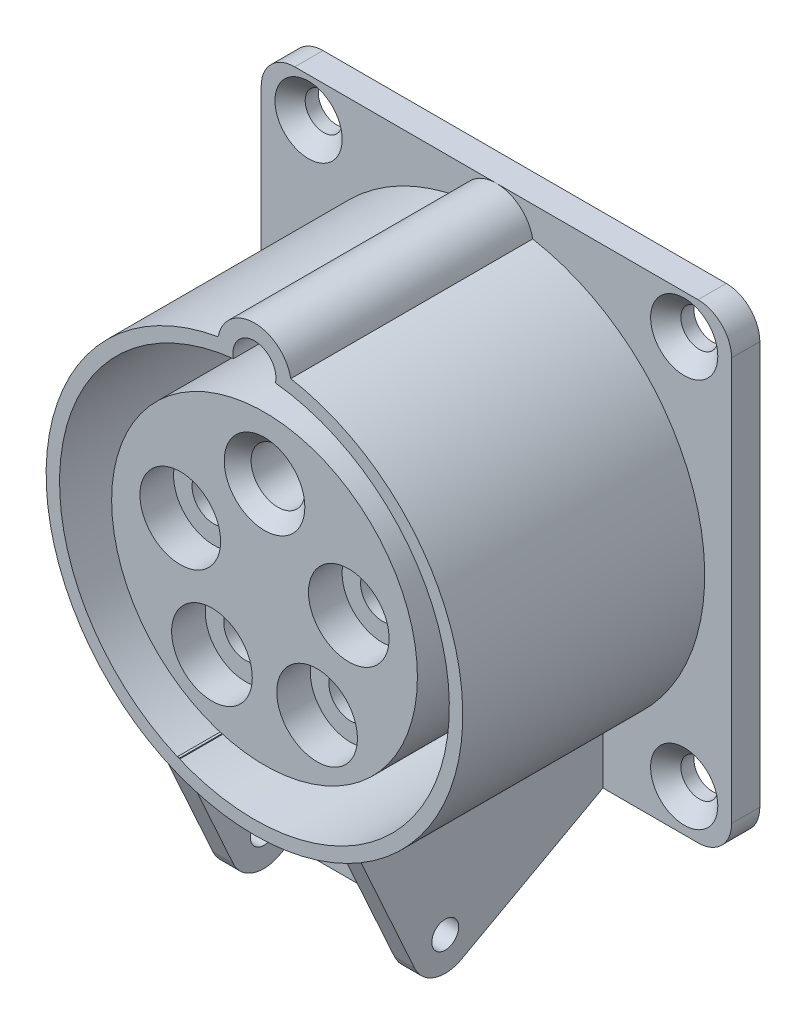
from build123d import *

# Parameters (mm, degrees)
BOSS_EXTRUDE1_DEPTH      = 36
SKETCH4_W                = 70
SKETCH4_H                = 70
SKETCH4_R                = 2.75
BOSS_EXTRUDE2_DEPTH      = 4.2
FILLET1_R                = 5
SKETCH3_R                = 22.75
CUT_EXTRUDE1_DEPTH       = 38.5
SKETCH7_R                = 22.75
CUT_EXTRUDE2_DEPTH       = 1.5
SKETCH9_R                = 6
CUT_EXTRUDE3_DEPTH       = 5
SKETCH11_R               = 3.25
CUT_EXTRUDE4_DEPTH       = 12
SKETCH12_R               = 4
CUT_EXTRUDE5_DEPTH       = 22.7
SKETCH14_R               = 4
CUT_EXTRUDE6_DEPTH       = 8
CHAMFER1_SIZE            = 2
SKETCH15_R               = 5
CUT_EXTRUDE7_DEPTH       = 31.7
SKETCH16_R               = 27.5
SKETCH16_R_2             = 25.2
BOSS_EXTRUDE3_DEPTH      = 2.7
SKETCH17_R               = 2
BOSS_EXTRUDE4_DEPTH      = 3
BOSS_EXTRUDE5_DEPTH      = 0.8
BOSS_EXTRUDE5_DEPTH_BACK = 0.8
SKETCH20_W               = 24
SKETCH20_H               = 22.523679835
BOSS_EXTRUDE6_DEPTH      = 2
FILLET2_R                = 5
CHAMFER2_SIZE            = 2.25


with BuildPart() as part:
    # Sketch2 → Boss-Extrude1 (new body)
    with BuildSketch(Plane.XY):
        with BuildLine():
            ThreePointArc((-6.268429979, 33.450707057), (-0.864865769, -28.074716672), (4.538698442, 33.450707057))
            ThreePointArc((4.538698442, 33.450707057), (-0.864865769, 37.925283328), (-6.268429979, 33.450707057))
        make_face()
    extrude(amount=BOSS_EXTRUDE1_DEPTH)

    # Sketch4 → Boss-Extrude2 (add)
    with BuildSketch(Plane(origin=(0, 0, 0), x_dir=(-1, 0, 0), z_dir=(0, 0, -1))):
        with Locations((0.864865769, 2.925283328)):
            Rectangle(SKETCH4_W, SKETCH4_H)
        with Locations((-27.085134231, -25.824716672)):
            Circle(SKETCH4_R, mode=Mode.SUBTRACT)
        with Locations((-27.085134231, 32.109962946)):
            Circle(SKETCH4_R, mode=Mode.SUBTRACT)
        with Locations((28.814865769, 32.109962946)):
            Circle(SKETCH4_R, mode=Mode.SUBTRACT)
        with Locations((28.814865769, -25.824716672)):
            Circle(SKETCH4_R, mode=Mode.SUBTRACT)
    extrude(amount=BOSS_EXTRUDE2_DEPTH)

    # Fillet1
    fillet1_edges = [part.edges().sort_by_distance(p)[0] for p in [
        (-35.864865769, -32.074716672, -2.1),
        (-35.864865769, 37.925283328, -2.1),
        (34.135134231, 37.925283328, -2.1),
        (34.135134231, -32.074716672, -2.1),
    ]]
    fillet(fillet1_edges, radius=FILLET1_R)

    # Sketch3 → Cut-Extrude1 (cut)
    with BuildSketch(Plane.XY.offset(36)):
        with BuildLine():
            ThreePointArc((-3.994084204, 31.755961294), (-0.864865769, -26.074716672), (2.264352666, 31.755961294))
            ThreePointArc((2.264352666, 31.755961294), (-0.864865769, 35.625283328), (-3.994084204, 31.755961294))
        make_face()
        with Locations((-0.864865769, 2.925283328)):
            Circle(SKETCH3_R, mode=Mode.SUBTRACT)
    extrude(amount=-CUT_EXTRUDE1_DEPTH, mode=Mode.SUBTRACT)

    # Sketch7 → Cut-Extrude2 (cut)
    with BuildSketch(Plane.XY.offset(36)):
        with Locations((-0.864865769, 2.925283328)):
            Circle(SKETCH7_R)
    extrude(amount=-CUT_EXTRUDE2_DEPTH, mode=Mode.SUBTRACT)

    # Sketch9 → Cut-Extrude3 (cut)
    with BuildSketch(Plane.XY.offset(34.5)):
        with Locations((-8.68550449, -9.468077043)):
            Circle(SKETCH9_R)
        with Locations((-13.403571753, 5.757891252)):
            Circle(SKETCH9_R)
        with Locations((11.673840215, 5.757891252)):
            Circle(SKETCH9_R)
        with Locations((6.955772953, -9.468077043)):
            Circle(SKETCH9_R)
    extrude(amount=-CUT_EXTRUDE3_DEPTH, mode=Mode.SUBTRACT)

    # Sketch11 → Cut-Extrude4 (cut)
    with BuildSketch(Plane.XY.offset(29.5)):
        with Locations((11.673840215, 5.757891252)):
            Circle(SKETCH11_R)
        with Locations((-13.403571753, 5.757891252)):
            Circle(SKETCH11_R)
        with Locations((-8.68550449, -9.468077043)):
            Circle(SKETCH11_R)
        with Locations((6.955772953, -9.468077043)):
            Circle(SKETCH11_R)
    extrude(amount=-CUT_EXTRUDE4_DEPTH, mode=Mode.SUBTRACT)

    # Sketch12 → Cut-Extrude5 (cut, through all)
    with BuildSketch(Plane.XY.offset(17.5)):
        with Locations((11.673840215, 5.757891252)):
            Circle(SKETCH12_R)
        with Locations((6.955772953, -9.468077043)):
            Circle(SKETCH12_R)
        with Locations((-8.68550449, -9.468077043)):
            Circle(SKETCH12_R)
        with Locations((-13.403571753, 5.757891252)):
            Circle(SKETCH12_R)
    extrude(amount=-CUT_EXTRUDE5_DEPTH, mode=Mode.SUBTRACT)

    # Sketch14 → Cut-Extrude6 (cut)
    with BuildSketch(Plane.XY.offset(34.5)):
        with Locations((-0.864865769, 16.425283328)):
            Circle(SKETCH14_R)
    extrude(amount=-CUT_EXTRUDE6_DEPTH, mode=Mode.SUBTRACT)

    # Chamfer1
    chamfer1_edges = [part.edges().sort_by_distance(p)[0] for p in [
        (-4.864865769, 16.425283328, 34.5),
    ]]
    chamfer(chamfer1_edges, length=CHAMFER1_SIZE)

    # Sketch15 → Cut-Extrude7 (cut, through all)
    with BuildSketch(Plane.XY.offset(26.5)):
        with Locations((-0.864865769, 16.425283328)):
            Circle(SKETCH15_R)
    extrude(amount=-CUT_EXTRUDE7_DEPTH, mode=Mode.SUBTRACT)

    # Sketch16 → Boss-Extrude3 (add)
    with BuildSketch(Plane(origin=(0, 0, -4.2), x_dir=(-1, 0, 0), z_dir=(0, 0, -1))):
        with Locations((0.864865769, 2.925283328)):
            Circle(SKETCH16_R)
        with Locations((0.864865769, 2.925283328)):
            Circle(SKETCH16_R_2, mode=Mode.SUBTRACT)
    extrude(amount=BOSS_EXTRUDE3_DEPTH)

    # Sketch17 → Boss-Extrude4 (add)
    with BuildSketch(Plane(origin=(15, 0, 0), x_dir=(0, 0, -1), z_dir=(1, 0, 0))):
        Polygon((-36, -23.70751664), (-25.8, -46.20751664), (0, -32.074716672), (0, -23.70751664), align=None)
        with Locations((-23.472627315, -39.231599401)):
            Circle(SKETCH17_R, mode=Mode.SUBTRACT)
    boss_extrude4 = extrude(amount=-BOSS_EXTRUDE4_DEPTH)

    # Mirror1: Boss-Extrude4 across plane
    add(boss_extrude4.mirror(Plane(origin=(0, 0, 0), x_dir=(0, 0, 1), z_dir=(1, 0, 0))))

    # Sketch19 → Boss-Extrude5 (add, two sides)
    with BuildSketch(Plane(origin=(0, 0, 0), x_dir=(0, 0, -1), z_dir=(1, 0, 0))) as boss_extrude5_sk:
        Polygon((0, -26.005820793), (0, -32.074716672), (-18, -41.934809673), (-18, -26.005820793), align=None)
    extrude(amount=BOSS_EXTRUDE5_DEPTH)
    extrude(boss_extrude5_sk.sketch, amount=-BOSS_EXTRUDE5_DEPTH_BACK)

    # Sketch20 → Boss-Extrude6 (add, along a direction that is not the sketch's normal)
    with BuildSketch(Plane(origin=(0, -24.671603492, -13.514683606), x_dir=(1, 0, 0), z_dir=(0, -0.877035704, -0.480425201))):
        with Locations((0, 26.671342108)):
            Rectangle(SKETCH20_W, SKETCH20_H)
    extrude(amount=-BOSS_EXTRUDE6_DEPTH, dir=(0, -1, 0))

    # Fillet2
    fillet2_edges = [part.edges().sort_by_distance(p)[0] for p in [
        (13.5, -46.20751664, 25.8),
        (-13.5, -46.20751664, 25.8),
    ]]
    fillet(fillet2_edges, radius=FILLET2_R)

    # Chamfer2
    chamfer2_edges = [part.edges().sort_by_distance(p)[0] for p in [
        (29.835134231, -25.824716672, 0),
        (-26.064865769, 32.109962946, 0),
        (-26.064865769, -25.824716672, 0),
        (29.835134231, 32.109962946, 0),
    ]]
    chamfer(chamfer2_edges, length=CHAMFER2_SIZE)


solid = part.part
